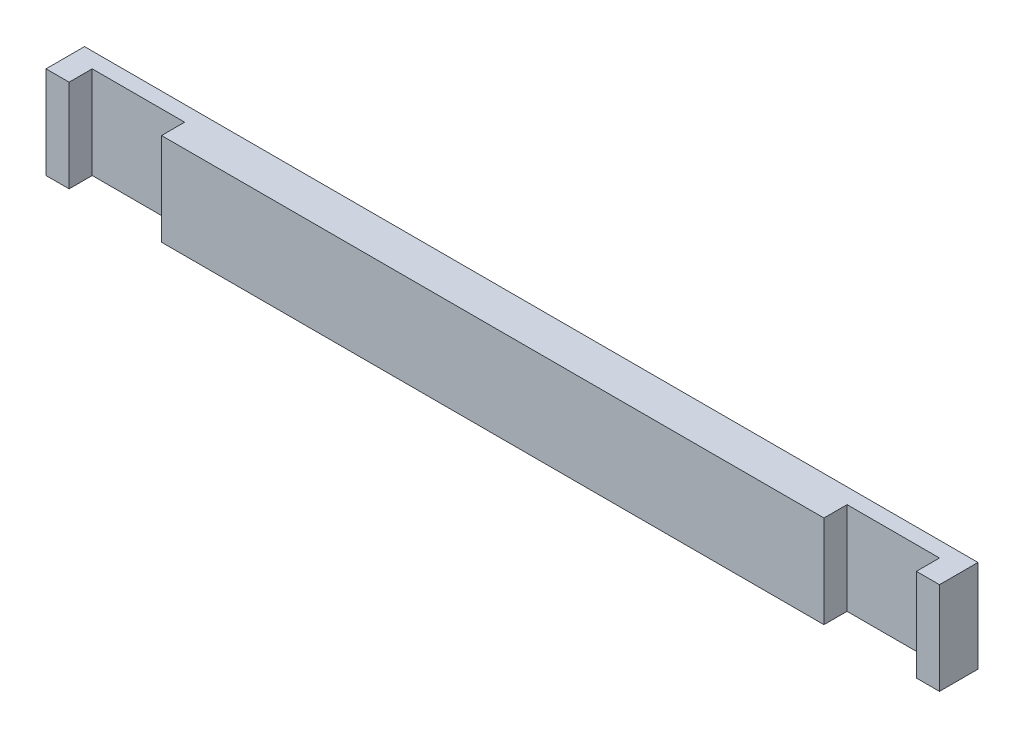
from build123d import *

# Parameters (mm, degrees)
EXTRUDE_1_DEPTH = 60


with BuildPart() as part:
    # Эскиз1 → Бобышка-Вытянуть1 (new body)
    with BuildSketch(Plane(origin=(0, 0, 0), x_dir=(1, 0, 0), z_dir=(0, 1, 0))):
        Polygon((215, 0), (-215, 0), (-215, 15), (-275, 15), (-275, 0), (-290, 0), (-290, 25), (290, 25), (290, 0), (275, 0), (275, 15), (215, 15), align=None)
    extrude(amount=EXTRUDE_1_DEPTH)


solid = part.part
